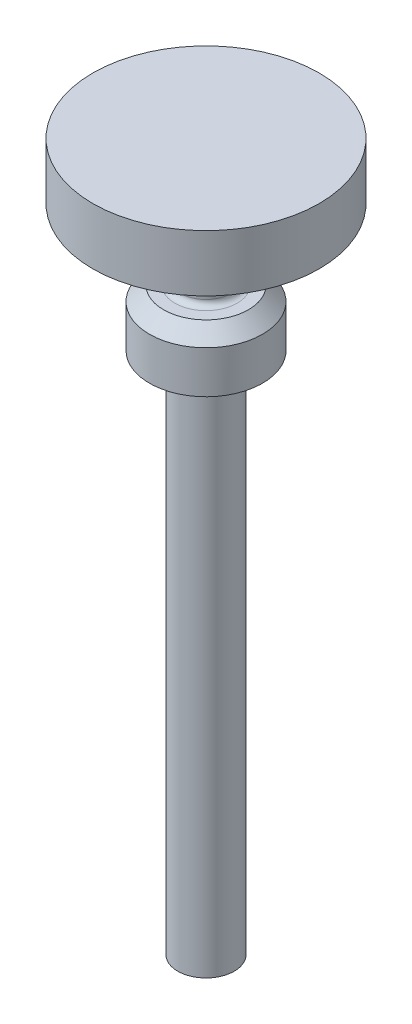
from build123d import *

# Parameters (mm, degrees)
CHAMFER1_SIZE = 0.5
FILLET1_R     = 0.2


with BuildPart() as part:
    # Sketch2 → Revolve1 (revolve)
    with BuildSketch(Plane.XY):
        Polygon((0, 0), (0, 25), (4, 25), (4, 23), (0.9, 23), (0.9, 20.5), (2, 20.5), (2, 18.5), (1, 18.5), (1, 0), align=None)
    revolve(axis=Axis((0, 0, 0), (0, 1, 0)))

    # Chamfer1
    chamfer1_edges = [part.edges().sort_by_distance(p)[0] for p in [
        (-2, 20.5, 0),
    ]]
    chamfer(chamfer1_edges, length=CHAMFER1_SIZE)

    # Fillet1
    fillet1_edges = [part.edges().sort_by_distance(p)[0] for p in [
        (-0.9, 23, 0),
        (-1, 18.5, 0),
        (-0.9, 20.5, 0),
    ]]
    fillet(fillet1_edges, radius=FILLET1_R)


solid = part.part
